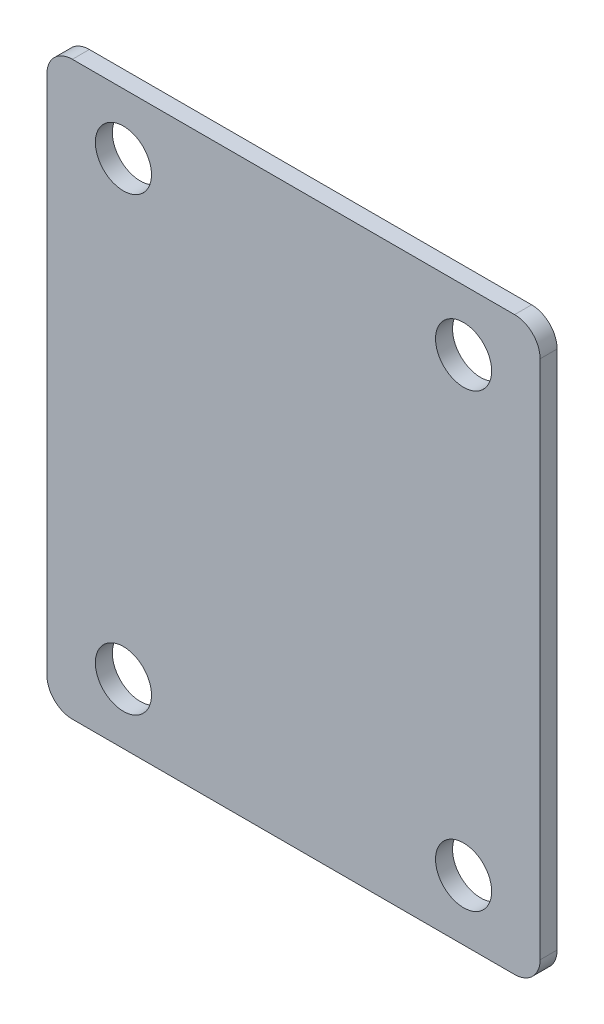
from build123d import *

# Parameters (mm, degrees)
SKETCH1_W            = 52
SKETCH1_H            = 61.2
BOSS_EXTRUDE1_DEPTH  = 2
M6_CLEARANCE_HOLE1_D = 6.6
SKETCH4_W            = 52
SKETCH4_H            = 61.2
BOSS_EXTRUDE2_DEPTH  = 2


with BuildPart() as part:
    # Sketch1 → Boss-Extrude1 (new body)
    with BuildSketch(Plane.XY):
        Rectangle(SKETCH1_W, SKETCH1_H)
    extrude(amount=BOSS_EXTRUDE1_DEPTH)

    # M6 Clearance Hole1 (through all)
    with Locations(Plane.XY.offset(2)):
        with Locations((20, -26.5), (-20, -26.5), (-20, 26.5), (20, 26.5)):
            Hole(M6_CLEARANCE_HOLE1_D / 2)

    # Sketch4 → Boss-Extrude2 (add)
    with BuildSketch(Plane.XY.offset(2)):
        with BuildLine():
            Line((-26, 33.6), (26, 33.6))
            ThreePointArc((26, 33.6), (28.121320344, 32.721320344), (29, 30.6))
            Line((29, 30.6), (29, -30.6))
            ThreePointArc((29, -30.6), (28.121320344, -32.721320344), (26, -33.6))
            Line((26, -33.6), (-26, -33.6))
            ThreePointArc((-26, -33.6), (-28.121320344, -32.721320344), (-29, -30.6))
            Line((-29, -30.6), (-29, 30.6))
            ThreePointArc((-29, 30.6), (-28.121320344, 32.721320344), (-26, 33.6))
        make_face()
        Rectangle(SKETCH4_W, SKETCH4_H, mode=Mode.SUBTRACT)
    extrude(amount=-BOSS_EXTRUDE2_DEPTH)


solid = part.part
